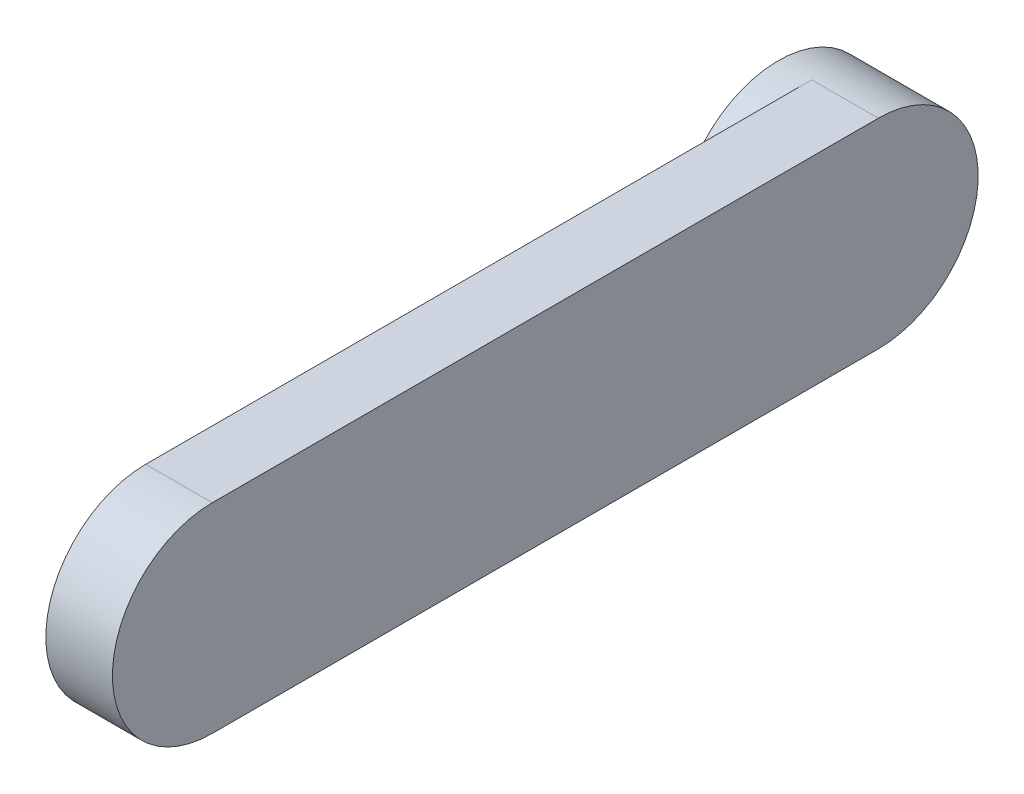
from build123d import *

# Parameters (mm, degrees)
EXTRUDE_1_DEPTH = 20
SKETCH_2_R      = 30
EXTRUDE_2_DEPTH = 10


with BuildPart() as part:
    # 草图1 → 凸台-拉伸1 (new body)
    with BuildSketch(Plane(origin=(0, 0, 0), x_dir=(0, 0, -1), z_dir=(1, 0, 0))):
        with BuildLine():
            Line((0, 30), (-200, 30))
            ThreePointArc((-200, 30), (-230, 0), (-200, -30))
            Line((-200, -30), (0, -30))
            ThreePointArc((0, -30), (30, 0), (0, 30))
        make_face()
    extrude(amount=EXTRUDE_1_DEPTH)

    # 草图2 → 凸台-拉伸2 (add)
    with BuildSketch(Plane.ZY):
        Circle(SKETCH_2_R)
    extrude(amount=EXTRUDE_2_DEPTH)


solid = part.part
